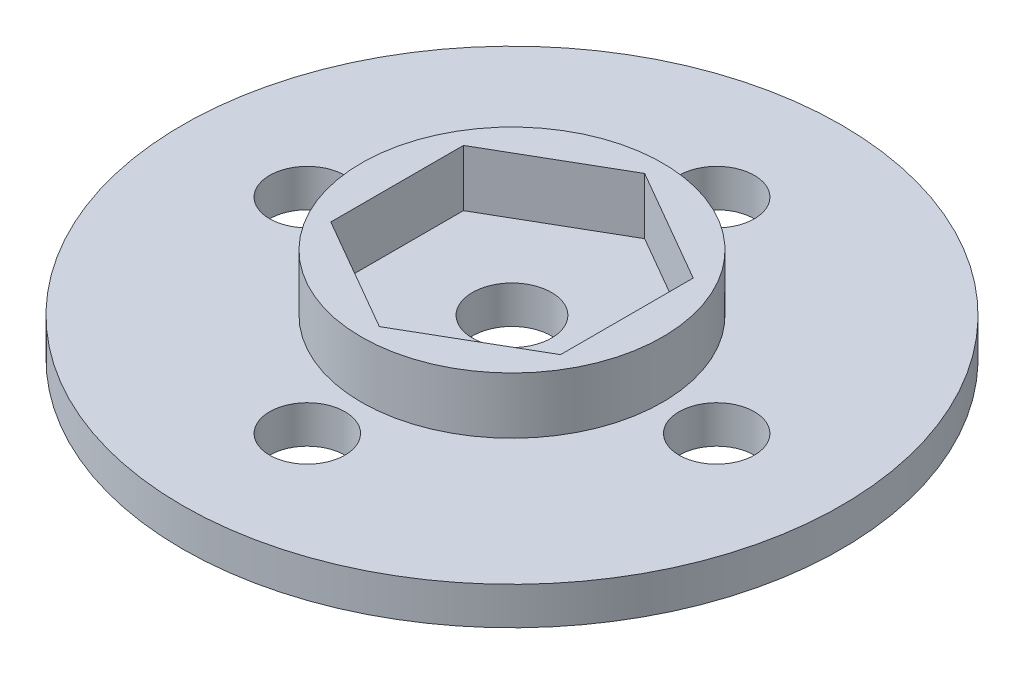
from build123d import *

# Parameters (mm, degrees)
SKETCH4_R               = 17.5
SKETCH4_R_2             = 2
BOSS_EXTRUDE1_DEPTH     = 2
SKETCH5_R               = 8
BOSS_EXTRUDE2_DEPTH     = 5
SKETCH6_R               = 2.1
CUT_EXTRUDE1_DEPTH      = 6
CUT_EXTRUDE1_DEPTH_BACK = 1


with BuildPart() as part:
    # Sketch4 → Boss-Extrude1 (new body)
    with BuildSketch(Plane(origin=(0, 0, 0), x_dir=(1, 0, 0), z_dir=(0, 1, 0))):
        Circle(SKETCH4_R)
        with Locations((10.87, 0)):
            Circle(SKETCH4_R_2, mode=Mode.SUBTRACT)
        with Locations((0, -10.87)):
            Circle(SKETCH4_R_2, mode=Mode.SUBTRACT)
        with Locations((-10.87, 0)):
            Circle(SKETCH4_R_2, mode=Mode.SUBTRACT)
        with Locations((0, 10.87)):
            Circle(SKETCH4_R_2, mode=Mode.SUBTRACT)
    extrude(amount=BOSS_EXTRUDE1_DEPTH)

    # Sketch5 → Boss-Extrude2 (add)
    with BuildSketch(Plane(origin=(0, 0, 0), x_dir=(-1, 0, 0), z_dir=(0, 1, 0))):
        Circle(SKETCH5_R)
        Polygon((-6.1, -3.521836642), (0, -7.043673284), (6.1, -3.521836642), (6.1, 3.521836642), (0, 7.043673284), (-6.1, 3.521836642), align=None, mode=Mode.SUBTRACT)
    extrude(amount=BOSS_EXTRUDE2_DEPTH)

    # Sketch6 → Cut-Extrude1 (cut, two sides)
    with BuildSketch(Plane(origin=(0, 0, 0), x_dir=(1, 0, 0), z_dir=(0, 1, 0))) as cut_extrude1_sk:
        Circle(SKETCH6_R)
    extrude(amount=CUT_EXTRUDE1_DEPTH, mode=Mode.SUBTRACT)
    extrude(cut_extrude1_sk.sketch, amount=-CUT_EXTRUDE1_DEPTH_BACK, mode=Mode.SUBTRACT)


solid = part.part
